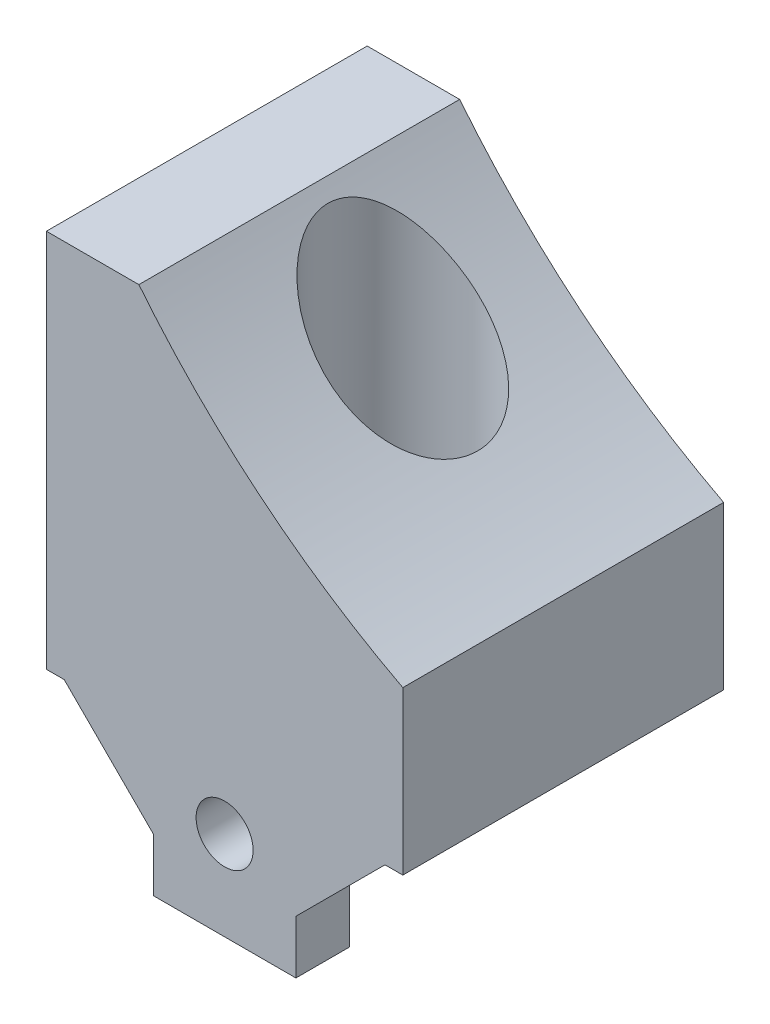
from build123d import *

# Parameters (mm, degrees)
EXTRUDE_1_DEPTH     = 18
SKETCH_6_R          = 4.2
CUT_EXTRUDE_1_DEPTH = 28
EXTRUDE_2_DEPTH     = 8
CHAMFER_1_SIZE      = 5
CHAMFER_2_SIZE      = 5
SKETCH_8_R          = 1.6
CUT_EXTRUDE_2_DEPTH = 8


with BuildPart() as part:
    # 草图1 → 凸台-拉伸1 (new body)
    with BuildSketch(Plane.XY):
        with BuildLine():
            Line((0, 0), (20, 0))
            Line((20, 0), (20, 9.111319982))
            ThreePointArc((20, 9.111319982), (11.967350423, 14.437400737), (5.19, 21.29))
            Line((5.19, 21.29), (0, 21.29))
            Line((0, 21.29), (0, 0))
        make_face()
    extrude(amount=EXTRUDE_1_DEPTH)

    # 草图6 → 切除-拉伸1 (cut)
    with BuildSketch(Plane.XZ):
        with Locations((10, 8)):
            Circle(SKETCH_6_R)
    extrude(amount=-CUT_EXTRUDE_1_DEPTH, mode=Mode.SUBTRACT)

    # 草图7 → 凸台-拉伸2 (add)
    with BuildSketch(Plane.XZ):
        Polygon((10, 18), (6, 18), (6, 15), (14, 15), (14, 18), align=None)
    extrude(amount=EXTRUDE_2_DEPTH)

    # 倒角1
    chamfer_1_edges = [part.edges().sort_by_distance(p)[0] for p in [
        (14, 0, 16.5),
    ]]
    chamfer(chamfer_1_edges, length=CHAMFER_1_SIZE)

    # 倒角2
    chamfer_2_edges = [part.edges().sort_by_distance(p)[0] for p in [
        (6, 0, 16.5),
    ]]
    chamfer(chamfer_2_edges, length=CHAMFER_2_SIZE)

    # 草图8 → 切除-拉伸2 (cut)
    with BuildSketch(Plane(origin=(0, 0, 15), x_dir=(-1, 0, 0), z_dir=(0, 0, -1))):
        with Locations((-10, -3)):
            Circle(SKETCH_8_R)
    extrude(amount=-CUT_EXTRUDE_2_DEPTH, mode=Mode.SUBTRACT)


solid = part.part
